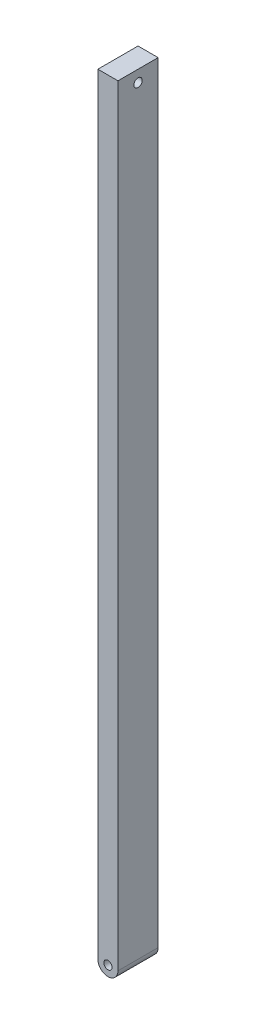
from build123d import *

# Parameters (mm, degrees)
SKETCH5_R           = 0.203870929
BOSS_EXTRUDE2_DEPTH = 2
SKETCH7_R           = 0.208826812
CUT_EXTRUDE5_DEPTH  = 2


with BuildPart() as part:
    # Sketch5 → Boss-Extrude2 (new body)
    with BuildSketch(Plane.XY):
        with BuildLine():
            Line((-1, -3.107995304), (-1, -40.897995304))
            ThreePointArc((-1, -40.897995304), (-0.5, -41.397995304), (0, -40.897995304))
            Line((0, -40.897995304), (0, -3.107995304))
            Line((0, -3.107995304), (0, -2.527995304))
            Line((0, -2.527995304), (-1, -2.527995304))
            Line((-1, -2.527995304), (-1, -3.107995304))
        make_face()
        with Locations((-0.5, -40.897995304)):
            Circle(SKETCH5_R, mode=Mode.SUBTRACT)
    extrude(amount=BOSS_EXTRUDE2_DEPTH)

    # Sketch7 → Cut-Extrude5 (cut, through all)
    with BuildSketch(Plane(origin=(0, 0, 0), x_dir=(0, 0, -1), z_dir=(1, 0, 0))):
        with Locations((-1, -3.107995304)):
            Circle(SKETCH7_R)
    extrude(amount=-CUT_EXTRUDE5_DEPTH, mode=Mode.SUBTRACT)


solid = part.part
